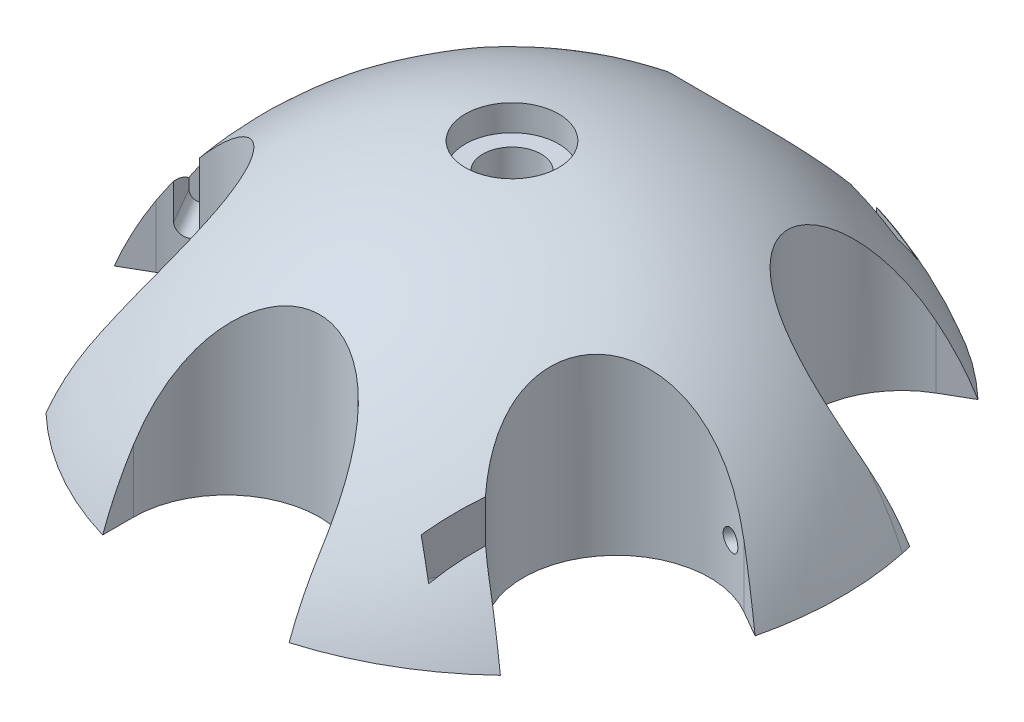
from build123d import *

# Parameters (mm, degrees)
SKETCH2_R          = 80.052532967
CUT_EXTRUDE1_DEPTH = 81
CUT_EXTRUDE2_DEPTH = 41
CIRPATTERN1_COUNT  = 6
CUT_EXTRUDE3_START = -3
SKETCH7_R          = 1.75
CUT_EXTRUDE3_DEPTH = 42
CUT_EXTRUDE5_DEPTH = 23
CIRPATTERN2_COUNT  = 3
CUT_EXTRUDE6_DEPTH = 5
SKETCH13_R         = 5
CUT_EXTRUDE7_DEPTH = 41.0000001
SKETCH14_R         = 8
CUT_EXTRUDE8_DEPTH = 5


with BuildPart() as part:
    # Sketch1 → Revolve1 (revolve)
    with BuildSketch(Plane.XY):
        with BuildLine():
            Line((0, 60), (0, -60))
            ThreePointArc((0, -60), (-60, 0), (0, 60))
        make_face()
    revolve(axis=Axis((0, 60, 0), (0, -1, 0)))

    # Sketch2 → Cut-Extrude1 (cut, through all)
    with BuildSketch(Plane(origin=(0, 20, 0), x_dir=(1, 0, 0), z_dir=(0, 1, 0))):
        Circle(SKETCH2_R)
    extrude(amount=-CUT_EXTRUDE1_DEPTH, mode=Mode.SUBTRACT)

    # Sketch6 → Cut-Extrude2 (cut, through all)
    with BuildSketch(Plane.XZ.offset(-20)):
        with BuildLine():
            Line((-34.426406871, 38.351303888), (-45.706213322, 44.863703179))
            Line((-45.706213322, 44.863703179), (-61.706213322, 17.150890258))
            Line((-61.706213322, 17.150890258), (-50.426406871, 10.638490967))
            ThreePointArc((-50.426406871, 10.638490967), (-28.570000411, 16.494897428), (-34.426406871, 38.351303888))
        make_face()
    cut_extrude2 = extrude(amount=-CUT_EXTRUDE2_DEPTH, mode=Mode.SUBTRACT)

    # CirPattern1: Cut-Extrude2 ×6 about axis
    cirpattern1_axis = Axis((0, 0, 0), (0, 1, 0))
    for i in range(1, CIRPATTERN1_COUNT):
        add(cut_extrude2.rotate(cirpattern1_axis, i * 360 / CIRPATTERN1_COUNT), mode=Mode.SUBTRACT)

    # Sketch7 → Cut-Extrude3 (cut)
    with BuildSketch(Plane(origin=(8, 0, 13.856406461), x_dir=(-0.866025404, 0, 0.5), z_dir=(-0.5, 0, -0.866025404)).offset(CUT_EXTRUDE3_START)):
        with Locations((45, 28)):
            Circle(SKETCH7_R)
    cut_extrude3 = extrude(amount=CUT_EXTRUDE3_DEPTH, mode=Mode.SUBTRACT)

    # Sketch11 → Cut-Extrude5 (cut)
    with BuildSketch(Plane(origin=(0, 0, 0), x_dir=(-0.866025404, 0, 0.5), z_dir=(-0.5, 0, -0.866025404))):
        with BuildLine():
            Line((46.75, 28), (46.75, 40.645857748))
            Line((46.75, 40.645857748), (43.25, 40.645857748))
            Line((43.25, 40.645857748), (43.25, 28))
            ThreePointArc((43.25, 28), (45, 26.25), (46.75, 28))
        make_face()
    cut_extrude5 = extrude(amount=CUT_EXTRUDE5_DEPTH, mode=Mode.SUBTRACT)

    # CirPattern2: Cut-Extrude3, Cut-Extrude5 ×3 about axis
    cirpattern2_axis = Axis((0, 0, 0), (0, 1, 0))
    for i in range(1, CIRPATTERN2_COUNT):
        add(cut_extrude3.rotate(cirpattern2_axis, i * 360 / CIRPATTERN2_COUNT), mode=Mode.SUBTRACT)
        add(cut_extrude5.rotate(cirpattern2_axis, i * 360 / CIRPATTERN2_COUNT), mode=Mode.SUBTRACT)

    # Sketch12 → Cut-Extrude6 (cut)
    with BuildSketch(Plane.XZ.offset(-20)):
        Polygon((15.588457268, -27), (31.176914536, 0), (15.588457268, 27), (-15.588457268, 27), (-31.176914536, 0), (-15.588457268, -27), align=None)
    extrude(amount=-CUT_EXTRUDE6_DEPTH, mode=Mode.SUBTRACT)

    # Sketch13 → Cut-Extrude7 (cut, through all)
    with BuildSketch(Plane(origin=(0, 60, 0), x_dir=(1, 0, 0), z_dir=(0, 1, 0))):
        Circle(SKETCH13_R)
    extrude(amount=-CUT_EXTRUDE7_DEPTH, mode=Mode.SUBTRACT)

    # Sketch14 → Cut-Extrude8 (cut)
    with BuildSketch(Plane(origin=(0, 60, 0), x_dir=(1, 0, 0), z_dir=(0, 1, 0))):
        Circle(SKETCH14_R)
    extrude(amount=-CUT_EXTRUDE8_DEPTH, mode=Mode.SUBTRACT)


solid = part.part
